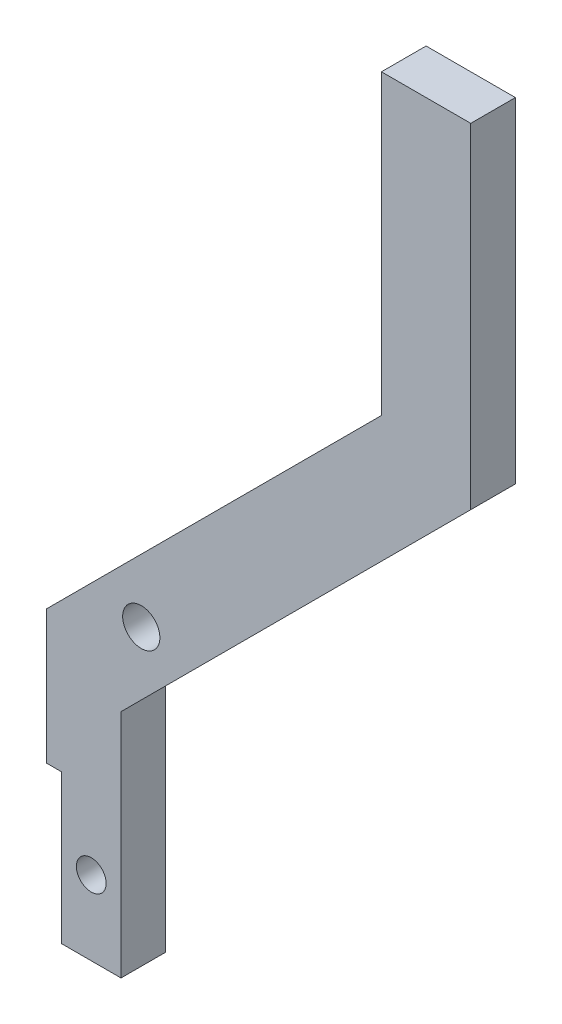
from build123d import *

# Parameters (mm, degrees)
BOSS_EXTRUDE1_DEPTH = 3
SKETCH3_W           = 2
SKETCH3_H           = 10
CUT_EXTRUDE2_DEPTH  = 3
SKETCH5_W           = 1
SKETCH5_H           = 12.104258702
CUT_EXTRUDE4_DEPTH  = 10
SKETCH6_R           = 1.25
CUT_EXTRUDE5_DEPTH  = 3
SKETCH7_R           = 1
CUT_EXTRUDE6_DEPTH  = 10


with BuildPart() as part:
    # Sketch1 → Boss-Extrude1 (new body)
    with BuildSketch(Plane.XY):
        Polygon((-29.183975781, -29.96919486), (-29.183975781, -14.46919486), (-5.683975781, 9.03080514), (-5.683975781, 31.516086514), (-11.683975781, 31.516086514), (-11.683975781, 11.516086514), (-35.183975781, -11.983913486), (-35.183975781, -29.96919486), align=None)
    extrude(amount=BOSS_EXTRUDE1_DEPTH)

    # Sketch3 → Cut-Extrude2 (cut)
    with BuildSketch(Plane.XY.offset(3)):
        with Locations((-34.183975781, -24.96919486)):
            Rectangle(SKETCH3_W, SKETCH3_H)
    extrude(amount=-CUT_EXTRUDE2_DEPTH, mode=Mode.SUBTRACT)

    # Sketch5 → Cut-Extrude4 (cut)
    with BuildSketch(Plane.XY.offset(3)):
        with Locations((-34.683975781, -13.917065509)):
            Rectangle(SKETCH5_W, SKETCH5_H)
    extrude(amount=-CUT_EXTRUDE4_DEPTH, mode=Mode.SUBTRACT)

    # Sketch6 → Cut-Extrude5 (cut)
    with BuildSketch(Plane.XY.offset(3)):
        with Locations((-27.823975781, -8.866554173)):
            Circle(SKETCH6_R)
    extrude(amount=-CUT_EXTRUDE5_DEPTH, mode=Mode.SUBTRACT)

    # Sketch7 → Cut-Extrude6 (cut)
    with BuildSketch(Plane.XY.offset(3)):
        with Locations((-31.183975781, -24.96919486)):
            Circle(SKETCH7_R)
    extrude(amount=-CUT_EXTRUDE6_DEPTH, mode=Mode.SUBTRACT)


solid = part.part
